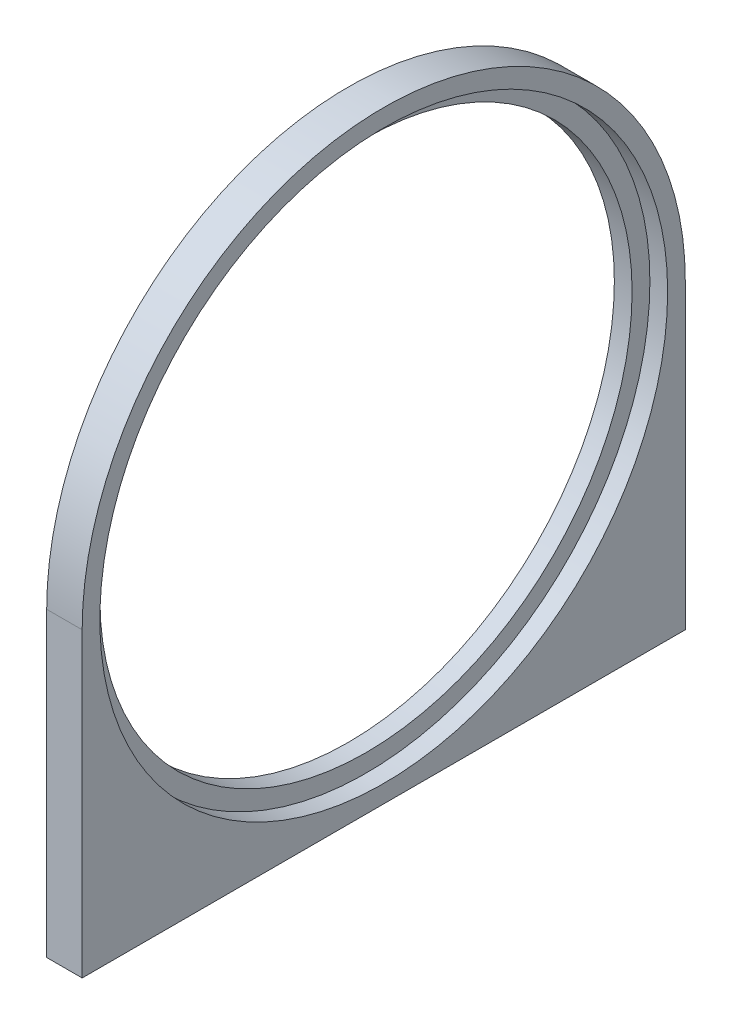
from build123d import *

# Parameters (mm, degrees)
SKETCH1_R                 = 50.8127
BOSS_EXTRUDE1_DEPTH       = 6.35
SKETCH1_3_R               = 50.8127
SKETCH1_3_R_2             = 47.625
BOSS_EXTRUDE2_DEPTH       = 3.175
F_8_32_TAPPED_HOLE3_D     = 3.4544
F_8_32_TAPPED_HOLE3_DEPTH = 6.35
F_8_32_TAPPED_HOLE3_TIP   = 1.037806461


with BuildPart() as part:
    # Sketch1 → Boss-Extrude1 (new body)
    with BuildSketch(Plane(origin=(0, 0, 0), x_dir=(0, 0, -1), z_dir=(1, 0, 0))):
        with BuildLine():
            ThreePointArc((53.975, 0), (0, 53.975), (-53.975, 0))
            Line((-53.975, 0), (-53.975, -53.975))
            Line((-53.975, -53.975), (53.975, -53.975))
            Line((53.975, -53.975), (53.975, 0))
        make_face()
        Circle(SKETCH1_R, mode=Mode.SUBTRACT)
    extrude(amount=BOSS_EXTRUDE1_DEPTH)

    # Sketch1_3 → Boss-Extrude2 (add)
    with BuildSketch(Plane(origin=(0, 0, 0), x_dir=(0, 0, -1), z_dir=(1, 0, 0))):
        Circle(SKETCH1_3_R)
        Circle(SKETCH1_3_R_2, mode=Mode.SUBTRACT)
    extrude(amount=BOSS_EXTRUDE2_DEPTH)

    # 8-32 Tapped Hole3
    with Locations(Plane(origin=(0, -53.975, 0), x_dir=(-1, 0, 0), z_dir=(0, -1, 0))):
        with Locations((-3.175, 44.45), (-3.175, 25.4), (-3.175, -25.4), (-3.175, -44.45)):
            Hole(F_8_32_TAPPED_HOLE3_D / 2, depth=F_8_32_TAPPED_HOLE3_DEPTH)
            with Locations((0, 0, -(F_8_32_TAPPED_HOLE3_DEPTH + F_8_32_TAPPED_HOLE3_TIP / 2))):  # 118° drill point
                Cone(0, F_8_32_TAPPED_HOLE3_D / 2, F_8_32_TAPPED_HOLE3_TIP, mode=Mode.SUBTRACT)


solid = part.part
